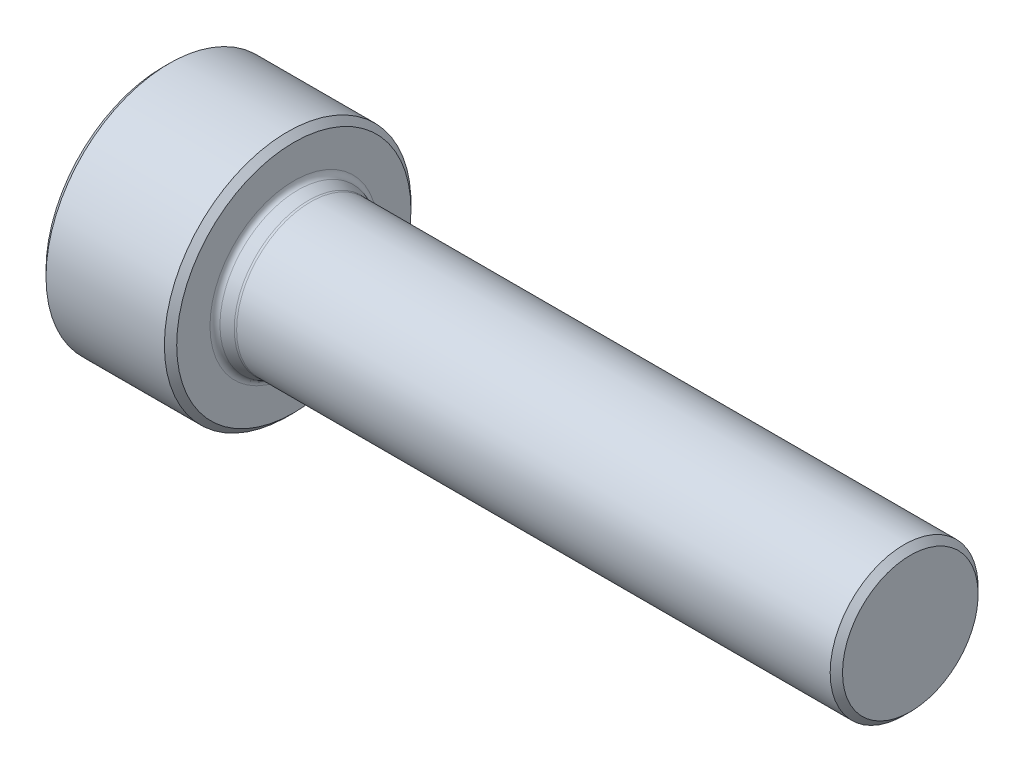
from build123d import *

# Parameters (mm, degrees)
CUT_EXTRUDE_1_DEPTH = 3
CHAMFER_1_SIZE      = 0.25


with BuildPart() as part:
    # Эскиз1 → Повернуть1 (revolve)
    with BuildSketch(Plane.XY):
        with BuildLine():
            Line((-4.982457352, 2.5), (-5.3, 3.05))
            Line((-5.3, 3.05), (-5.3, 5))
            Line((-5.3, 5), (0, 5))
            Line((0, 5), (0, 3.4))
            ThreePointArc((0, 3.4), (0.046179295, 3.255234258), (0.167656961, 3.163949955))
            Line((0.167656961, 3.163949955), (0.597656961, 3.013949955))
            ThreePointArc((0.597656961, 3.013949955), (0.638241835, 3.003512159), (0.68, 3))
            Line((0.68, 3), (25, 3))
            Line((25, 3), (25, 0))
            Line((25, 0), (-0.856624327, 0))
            Line((-0.856624327, 0), (-2.3, 2.5))
            Line((-2.3, 2.5), (-4.982457352, 2.5))
        make_face()
    revolve(axis=Axis((-1000, 0, 0), (1, 0, 0)))

    # Эскиз2 → Вырез-Вытянуть1 (cut)
    with BuildSketch(Plane.ZY.offset(5.3)):
        with BuildLine():
            Line((-0.038113557, 2.864746473), (-2.461886443, 1.465380546))
            ThreePointArc((-2.461886443, 1.465380546), (-2.481162782, 1.4325), (-2.5, 1.399365928))
            Line((-2.5, 1.399365928), (-2.5, -1.399365928))
            ThreePointArc((-2.5, -1.399365928), (-2.481162782, -1.4325), (-2.461886443, -1.465380546))
            Line((-2.461886443, -1.465380546), (-0.038113557, -2.864746473))
            ThreePointArc((-0.038113557, -2.864746473), (0, -2.865), (0.038113557, -2.864746473))
            Line((0.038113557, -2.864746473), (2.461886443, -1.465380546))
            ThreePointArc((2.461886443, -1.465380546), (2.481162782, -1.4325), (2.5, -1.399365928))
            Line((2.5, -1.399365928), (2.5, 1.399365928))
            ThreePointArc((2.5, 1.399365928), (2.481162782, 1.4325), (2.461886443, 1.465380546))
            Line((2.461886443, 1.465380546), (0.038113557, 2.864746473))
            ThreePointArc((0.038113557, 2.864746473), (0, 2.865), (-0.038113557, 2.864746473))
        make_face()
    extrude(amount=-CUT_EXTRUDE_1_DEPTH, mode=Mode.SUBTRACT)

    # Фаска1
    chamfer_1_edges = [part.edges().sort_by_distance(p)[0] for p in [
        (-5.3, -5, 0),
        (0, -5, 0),
        (25, -3, 0),
    ]]
    chamfer(chamfer_1_edges, length=CHAMFER_1_SIZE)


solid = part.part
